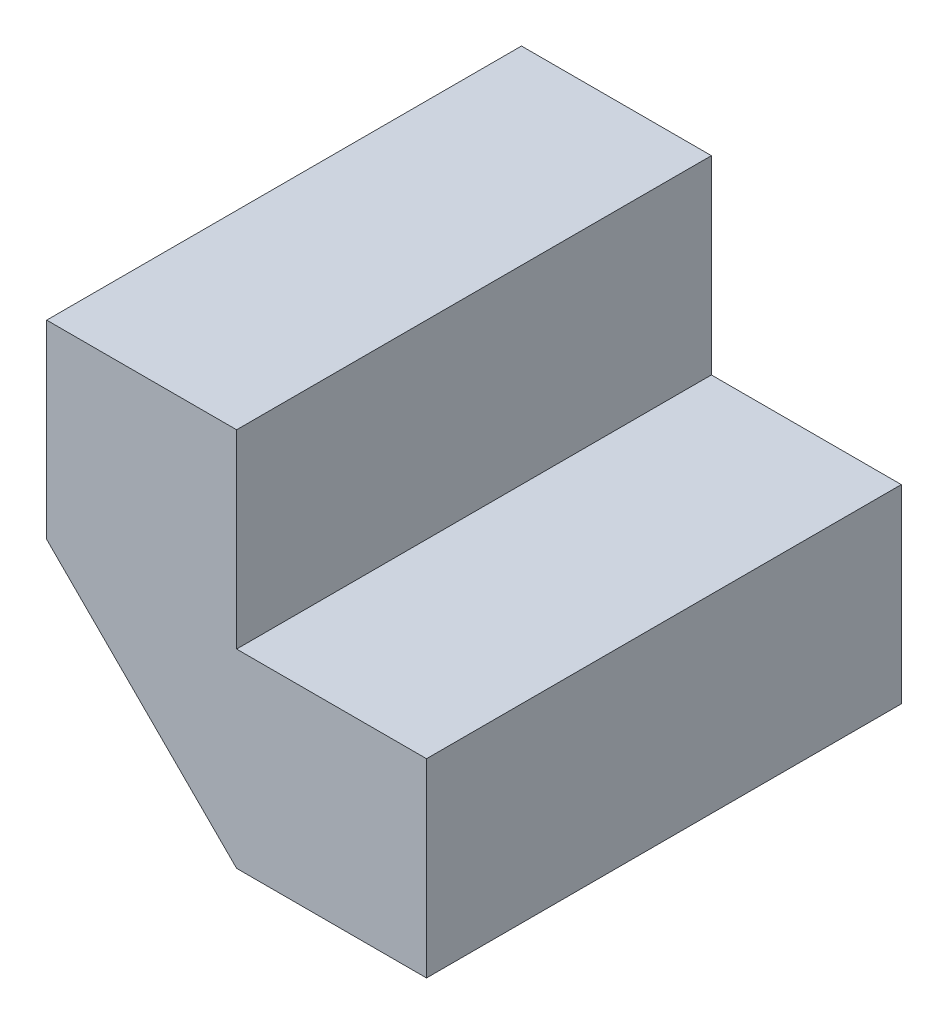
from build123d import *

# Parameters (mm, degrees)
BOSS_EXTRUDE1_DEPTH = 25


with BuildPart() as part:
    # Sketch1 → Boss-Extrude1 (new body)
    with BuildSketch(Plane.XY):
        Polygon((-20, 20), (-10, 20), (-10, 10), (0, 10), (0, 0), (-10, 0), (-20, 10), align=None)
    extrude(amount=BOSS_EXTRUDE1_DEPTH)


solid = part.part
